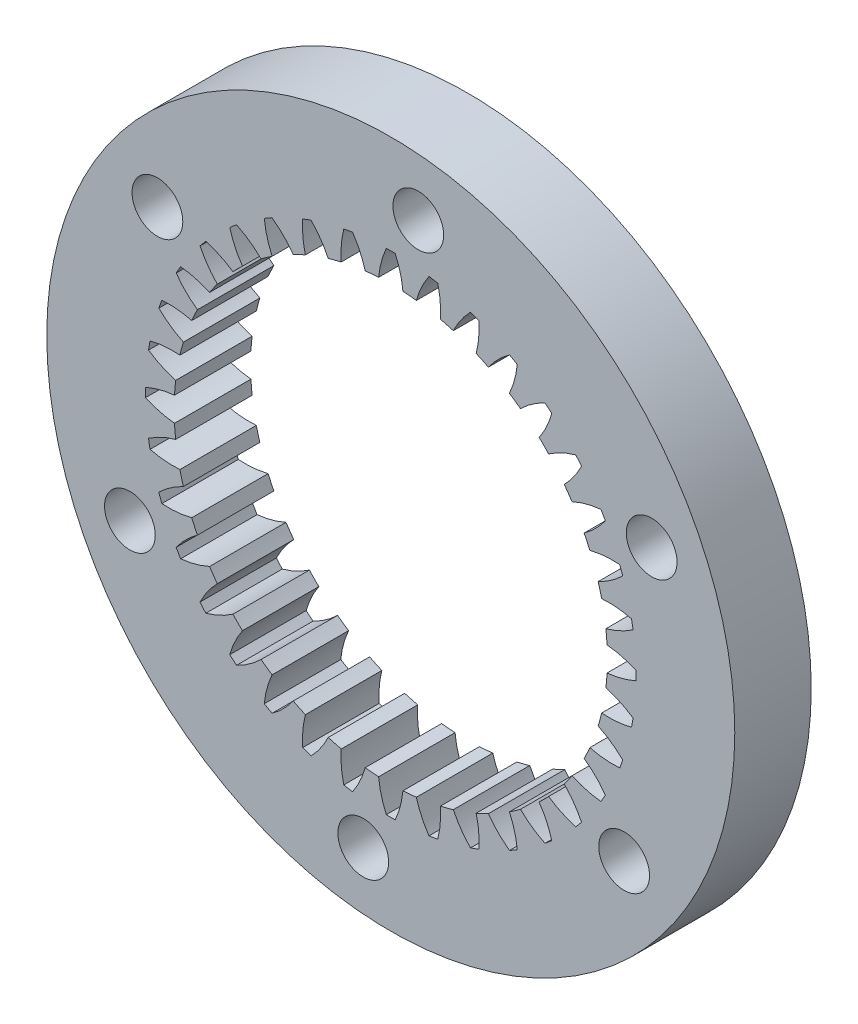
from build123d import *

# Parameters (mm, degrees)
GEARSKETCH_R       = 28.575
GEARBODY_DEPTH     = 6.35
BORESKETCH_R       = 17.991666667
BODYBORE_DEPTH     = 41.907013457
CUT_EXTRUDE2_DEPTH = 310.362980575
CIRPATTERN1_COUNT  = 36
SKETCH3_R          = 2.1082
VERSAKEY_DEPTH     = 41.907013457


with BuildPart() as part:
    # gearSketch → gearBody (new body)
    with BuildSketch(Plane.XY):
        Circle(GEARSKETCH_R)
    extrude(amount=GEARBODY_DEPTH)

    # boreSketch → bodyBore (cut, through all)
    with BuildSketch(Plane(origin=(0, 0, 0), x_dir=(-1, 0, 0), z_dir=(0, 0, -1))):
        Circle(BORESKETCH_R)
    extrude(amount=-BODYBORE_DEPTH, mode=Mode.SUBTRACT)

    # toothCut1 → Cut-Extrude2 (cut, through all)
    with BuildSketch(Plane(origin=(-279.4, 0, 0), x_dir=(-1, 0, 0), z_dir=(0, 0, -1))):
        with BuildLine():
            Line((-279.4, 0), (-280.409669091, 17.963313663))
            ThreePointArc((-280.409669091, 17.963313663), (-280.190100259, 19.192897751), (-279.771046109, 20.369537508))
            ThreePointArc((-279.771046109, 20.369537508), (-279.4, 20.372916667), (-279.028953891, 20.369537508))
            ThreePointArc((-279.028953891, 20.369537508), (-278.609899741, 19.192897751), (-278.390330909, 17.963313663))
            Line((-278.390330909, 17.963313663), (-279.4, 0))
        make_face()
    cut_extrude2 = extrude(amount=-CUT_EXTRUDE2_DEPTH, mode=Mode.SUBTRACT)

    # CirPattern1: Cut-Extrude2 ×36 about axis
    cirpattern1_axis = Axis((0, 0, -80.9), (0, 0, 1))
    for i in range(1, CIRPATTERN1_COUNT):
        add(cut_extrude2.rotate(cirpattern1_axis, i * 360 / CIRPATTERN1_COUNT), mode=Mode.SUBTRACT)

    # Sketch3 → Versakey (cut, through all)
    with BuildSketch(Plane.XY.offset(6.35)):
        with Locations((2.286, 23.702518015)):
            Circle(SKETCH3_R)
        with Locations((21.669982735, 9.871524934)):
            Circle(SKETCH3_R)
        with Locations((19.383982735, -13.830993081)):
            Circle(SKETCH3_R)
        with Locations((-2.286, -23.702518015)):
            Circle(SKETCH3_R)
        with Locations((-21.669982735, -9.871524934)):
            Circle(SKETCH3_R)
        with Locations((-19.383982735, 13.830993081)):
            Circle(SKETCH3_R)
    extrude(amount=-VERSAKEY_DEPTH, mode=Mode.SUBTRACT)


solid = part.part
